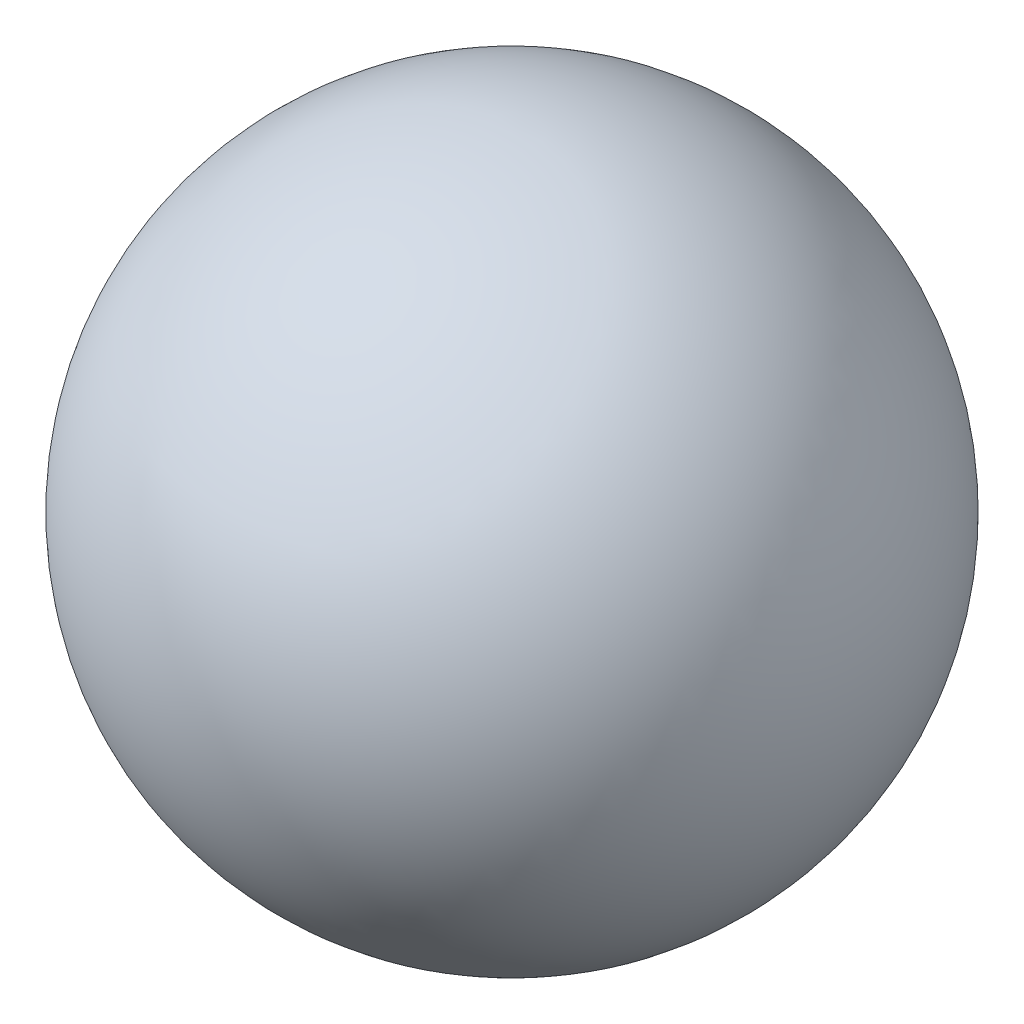
from build123d import *


with BuildPart() as part:
    # Sketch1 → Revolve1 (revolve)
    with BuildSketch(Plane.XY):
        with BuildLine():
            Line((0, 330.2), (0, 0))
            ThreePointArc((0, 0), (165.1, 165.1), (0, 330.2))
        make_face()
    revolve(axis=Axis((0, 0, 0), (0, 1, 0)))


solid = part.part
